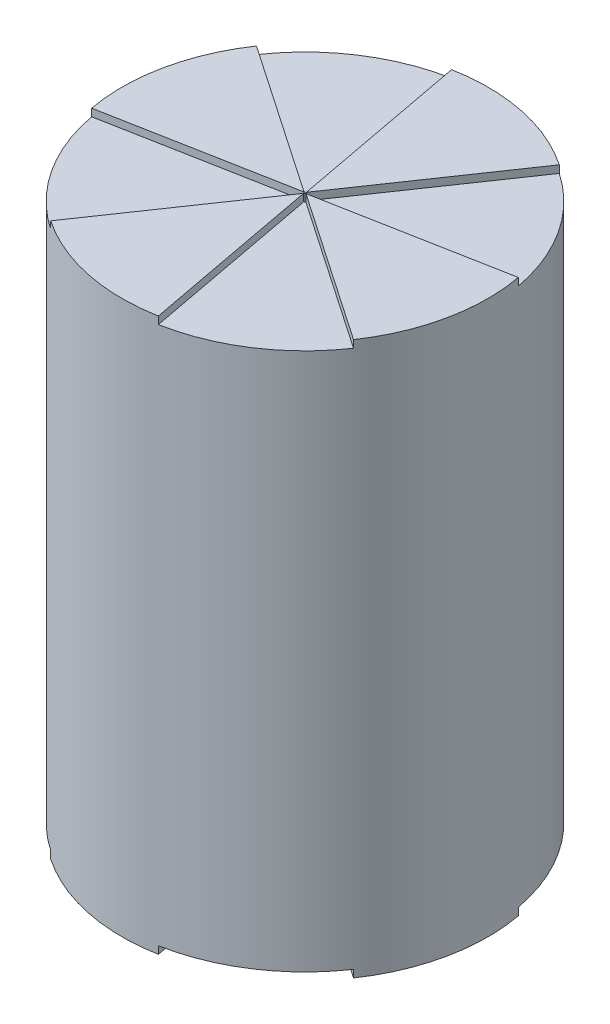
from build123d import *

# Parameters (mm, degrees)
SKETCH1_R            = 62.23
BOSS_EXTRUDE1_DEPTH  = 187.96
CUT_EXTRUDE7_DEPTH   = 2.54
CIRPATTERN2_COUNT    = 4
MIRROR1_COPY_1_DEPTH = 2.54
MIRROR1_COPY_2_DEPTH = 2.54
MIRROR1_COPY_3_DEPTH = 2.54


with BuildPart() as part:
    # Sketch1 → Boss-Extrude1 (new body)
    with BuildSketch(Plane(origin=(0, 0, 0), x_dir=(1, 0, 0), z_dir=(0, 1, 0))):
        Circle(SKETCH1_R)
    extrude(amount=BOSS_EXTRUDE1_DEPTH)

    # Sketch2 → Cut-Extrude7 (cut)
    with BuildSketch(Plane(origin=(0, 187.96, 0), x_dir=(1, 0, 0), z_dir=(0, 1, 0))):
        with BuildLine():
            Line((-34.977816307, -51.46965384), (0.021593035, -0.253080503))
            ThreePointArc((0.021593035, -0.253080503), (-0.212652586, -0.138906004), (-0.223069042, 0.12147511))
            Line((-0.223069042, 0.12147511), (-61.186975042, -11.345791522))
            ThreePointArc((-61.186975042, -11.345791522), (-52.099883451, -34.031970915), (-34.977816307, -51.46965384))
        make_face()
    cut_extrude7 = extrude(amount=-CUT_EXTRUDE7_DEPTH, mode=Mode.SUBTRACT)

    # CirPattern2: Cut-Extrude7 ×4 about axis
    cirpattern2_axis = Axis((0, 0, 0), (0, 1, 0))
    for i in range(1, CIRPATTERN2_COUNT):
        add(cut_extrude7.rotate(cirpattern2_axis, i * 360 / CIRPATTERN2_COUNT), mode=Mode.SUBTRACT)

    # Mirror1: Cut-Extrude7 across plane
    add(cut_extrude7.mirror(Plane.ZX.offset(93.98)), mode=Mode.SUBTRACT)

    # Mirror1 copy 1 sketch → Mirror1 copy 1 (cut)
    with BuildSketch(Plane(origin=(0, 0, 0), x_dir=(0, 0, -1), z_dir=(0, -1, 0))):
        with BuildLine():
            Line((-34.977816307, 51.46965384), (0.021593035, 0.253080503))
            ThreePointArc((0.021593035, 0.253080503), (-0.212652586, 0.138906004), (-0.223069042, -0.12147511))
            Line((-0.223069042, -0.12147511), (-61.186975042, 11.345791522))
            ThreePointArc((-61.186975042, 11.345791522), (-52.099883451, 34.031970915), (-34.977816307, 51.46965384))
        make_face()
    extrude(amount=-MIRROR1_COPY_1_DEPTH, mode=Mode.SUBTRACT)

    # Mirror1 copy 2 sketch → Mirror1 copy 2 (cut)
    with BuildSketch(Plane(origin=(0, 0, 0), x_dir=(-1, 0, 0), z_dir=(0, -1, 0))):
        with BuildLine():
            Line((-34.977816307, 51.46965384), (0.021593035, 0.253080503))
            ThreePointArc((0.021593035, 0.253080503), (-0.212652586, 0.138906004), (-0.223069042, -0.12147511))
            Line((-0.223069042, -0.12147511), (-61.186975042, 11.345791522))
            ThreePointArc((-61.186975042, 11.345791522), (-52.099883451, 34.031970915), (-34.977816307, 51.46965384))
        make_face()
    extrude(amount=-MIRROR1_COPY_2_DEPTH, mode=Mode.SUBTRACT)

    # Mirror1 copy 3 sketch → Mirror1 copy 3 (cut)
    with BuildSketch(Plane(origin=(0, 0, 0), x_dir=(0, 0, 1), z_dir=(0, -1, 0))):
        with BuildLine():
            Line((-34.977816307, 51.46965384), (0.021593035, 0.253080503))
            ThreePointArc((0.021593035, 0.253080503), (-0.212652586, 0.138906004), (-0.223069042, -0.12147511))
            Line((-0.223069042, -0.12147511), (-61.186975042, 11.345791522))
            ThreePointArc((-61.186975042, 11.345791522), (-52.099883451, 34.031970915), (-34.977816307, 51.46965384))
        make_face()
    extrude(amount=-MIRROR1_COPY_3_DEPTH, mode=Mode.SUBTRACT)


solid = part.part
